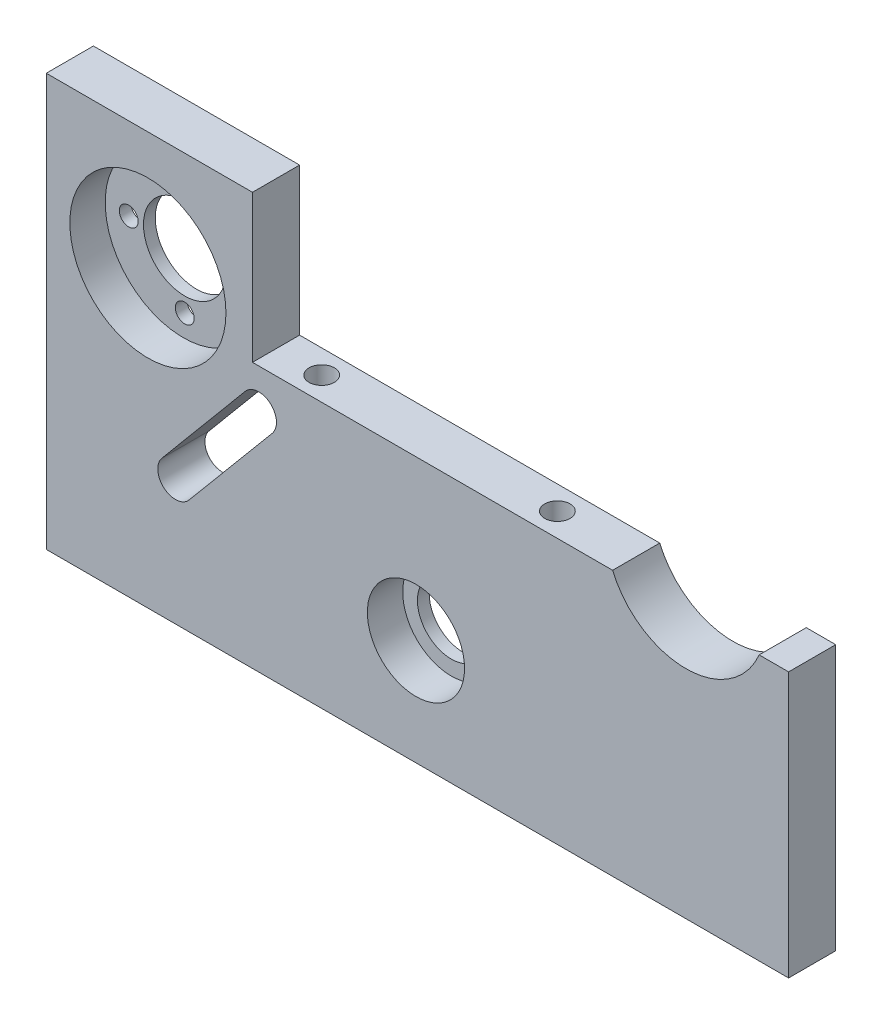
from build123d import *

# Parameters (mm, degrees)
BOSS_EXTRU_1_DEPTH       = 8
REPOSE_MOTEUR_DEPTH      = 8
ESQUISSE5_R              = 8.25
FIXATION_COURROI_1_DEPTH = 6
ESQUISSE6_R              = 5.75
FIXATION_COURROI_2_DEPTH = 2
ESQUISSE3_R              = 7
FIXATION_MOTEUR_1_DEPTH  = 2
ESQUISSE2_R              = 13.25
FIXATION_MOTEUR_2_DEPTH  = 6
D_GAGEMENT_M31_D         = 3.2
D_GAGEMENT_M31_DEPTH     = 10
D_GAGEMENT_M31_TIP       = 0.96137699
D_GAGEMENT_M41_D         = 4.3
D_GAGEMENT_M41_DEPTH     = 10
D_GAGEMENT_M41_TIP       = 1.291850331
ESQUISSE7_R              = 1.75
ENL_V_MAT_EXTRU_1_DEPTH  = 10


with BuildPart() as part:
    # Esquisse1 → Boss.-Extru.1 (new body)
    with BuildSketch(Plane.XY):
        Polygon((-53.385579659, 37.671052632), (-53.385579659, -32.328947368), (72.614420341, -32.328947368), (72.614420341, 12.671052632), (-18.385579659, 12.671052632), (-18.385579659, 37.671052632), align=None)
    extrude(amount=BOSS_EXTRU_1_DEPTH)

    # Esquisse4 → Repose moteur (cut)
    with BuildSketch(Plane.XY.offset(8)):
        with BuildLine():
            Line((42.741726231, 12.671052632), (67.614420341, 12.671052632))
            ThreePointArc((67.614420341, 12.671052632), (55.178073286, 4.423411332), (42.741726231, 12.671052632))
        make_face()
        with BuildLine():
            Line((-19.611662647, 7.796589582), (-33.760042708, -9.10286438))
            ThreePointArc((-33.760042708, -9.10286438), (-33.385579659, -13.328947368), (-29.15949667, -12.954484319))
            Line((-29.15949667, -12.954484319), (-15.011116609, 3.944969643))
            ThreePointArc((-15.011116609, 3.944969643), (-15.385579659, 8.171052632), (-19.611662647, 7.796589582))
        make_face()
    extrude(amount=-REPOSE_MOTEUR_DEPTH, mode=Mode.SUBTRACT)

    # Esquisse5 → Fixation courroi 1 (cut)
    with BuildSketch(Plane.XY.offset(8)):
        with Locations((9.364420341, -14.328947368)):
            Circle(ESQUISSE5_R)
    extrude(amount=-FIXATION_COURROI_1_DEPTH, mode=Mode.SUBTRACT)

    # Esquisse6 → Fixation courroi 2 (cut)
    with BuildSketch(Plane(origin=(0, 0, 0), x_dir=(-1, 0, 0), z_dir=(0, 0, -1))):
        with Locations((-9.364420341, -14.328947368)):
            Circle(ESQUISSE6_R)
    extrude(amount=-FIXATION_COURROI_2_DEPTH, mode=Mode.SUBTRACT)

    # Esquisse3 → Fixation moteur 1 (cut)
    with BuildSketch(Plane(origin=(0, 0, 0), x_dir=(-1, 0, 0), z_dir=(0, 0, -1))):
        with Locations((35.885579659, 17.671052632)):
            Circle(ESQUISSE3_R)
    extrude(amount=-FIXATION_MOTEUR_1_DEPTH, mode=Mode.SUBTRACT)

    # Esquisse2 → Fixation moteur 2 (cut)
    with BuildSketch(Plane.XY.offset(8)):
        with Locations((-36.135579659, 17.671052632)):
            Circle(ESQUISSE2_R)
    extrude(amount=-FIXATION_MOTEUR_2_DEPTH, mode=Mode.SUBTRACT)

    # Dégagement M31
    with Locations(Plane(origin=(-26.385579659, 17.671052632, 0), x_dir=(-1, 0, 0), z_dir=(0, 0, -1))):
        with Locations((0, 0), (9.5, 9.5), (19, 0), (9.5, -9.5)):
            Hole(D_GAGEMENT_M31_D / 2, depth=D_GAGEMENT_M31_DEPTH)
            with Locations((0, 0, -(D_GAGEMENT_M31_DEPTH + D_GAGEMENT_M31_TIP / 2))):  # 118° drill point
                Cone(0, D_GAGEMENT_M31_D / 2, D_GAGEMENT_M31_TIP, mode=Mode.SUBTRACT)

    # Dégagement M41
    with Locations(Plane(origin=(-10.635579659, 12.671052632, 4), x_dir=(1, 0, 0), z_dir=(0, 1, 0))):
        with Locations((0, 0), (40, 0)):
            Hole(D_GAGEMENT_M41_D / 2, depth=D_GAGEMENT_M41_DEPTH)
            with Locations((0, 0, -(D_GAGEMENT_M41_DEPTH + D_GAGEMENT_M41_TIP / 2))):  # 118° drill point
                Cone(0, D_GAGEMENT_M41_D / 2, D_GAGEMENT_M41_TIP, mode=Mode.SUBTRACT)

    # Esquisse7 → Enlèv. mat.-Extru.1 (cut)
    with BuildSketch(Plane.XZ.offset(32.328947368)):
        with Locations((-49.385579659, 3.800276617)):
            Circle(ESQUISSE7_R)
        with Locations((-14.385579659, 3.800276617)):
            Circle(ESQUISSE7_R)
        with Locations((37.614420341, 3.800276617)):
            Circle(ESQUISSE7_R)
        with Locations((68.614420341, 3.800276617)):
            Circle(ESQUISSE7_R)
    extrude(amount=-ENL_V_MAT_EXTRU_1_DEPTH, mode=Mode.SUBTRACT)


solid = part.part
